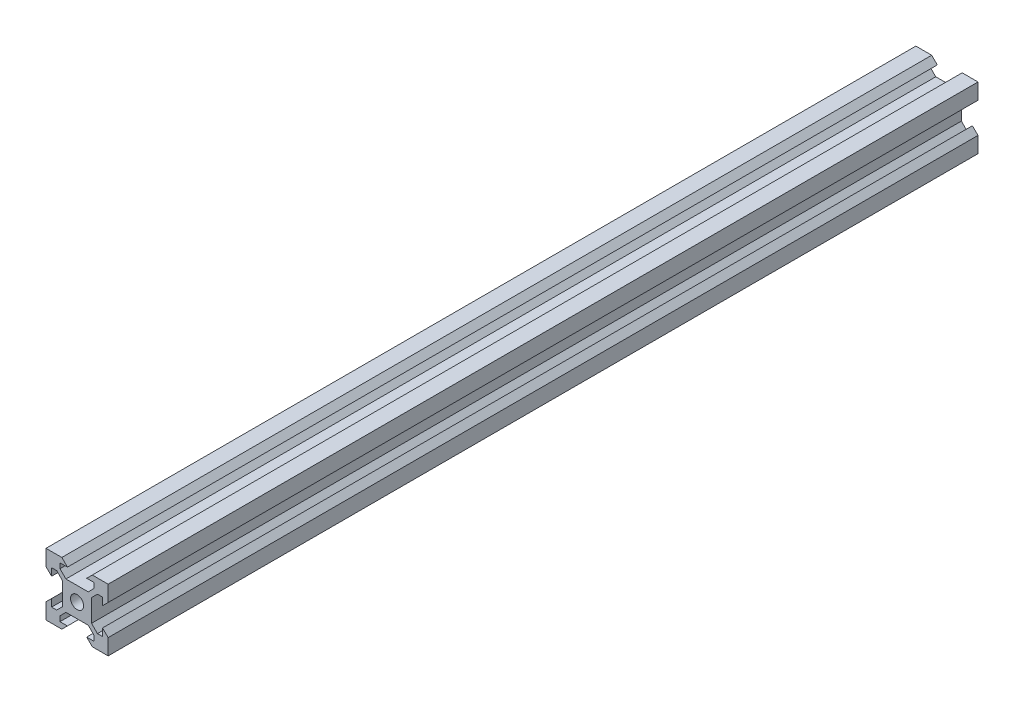
from build123d import *

# Parameters (mm, degrees)
SKETCH1_R           = 2.1
BOSS_EXTRUDE1_DEPTH = 140


with BuildPart() as part:
    # Sketch1 → Boss-Extrude1 (new body, symmetric)
    with BuildSketch(Plane.XY):
        Polygon((5.499339828, 6.56), (3.59, 4.650660172), (-3.59, 4.650660172), (-5.499339828, 6.56), (-5.499339828, 8.2), (-3.1, 8.2), (-4.9, 10), (-10, 10), (-10, 4.9), (-8.2, 3.1), (-8.2, 5.499339828), (-6.56, 5.499339828), (-4.650660172, 3.59), (-4.650660172, -3.59), (-6.56, -5.499339828), (-8.2, -5.499339828), (-8.2, -3.1), (-10, -4.9), (-10, -10), (-4.9, -10), (-3.1, -8.2), (-5.499339828, -8.2), (-5.499339828, -6.56), (-3.59, -4.650660172), (3.59, -4.650660172), (5.499339828, -6.56), (5.499339828, -8.2), (3.1, -8.2), (4.9, -10), (10, -10), (10, -4.9), (8.2, -3.1), (8.2, -5.499339828), (6.56, -5.499339828), (4.650660172, -3.59), (4.650660172, 3.59), (6.56, 5.499339828), (8.2, 5.499339828), (8.2, 3.1), (10, 4.9), (10, 10), (4.9, 10), (3.1, 8.2), (5.499339828, 8.2), align=None)
        Circle(SKETCH1_R, mode=Mode.SUBTRACT)
    extrude(amount=BOSS_EXTRUDE1_DEPTH, both=True)


solid = part.part
